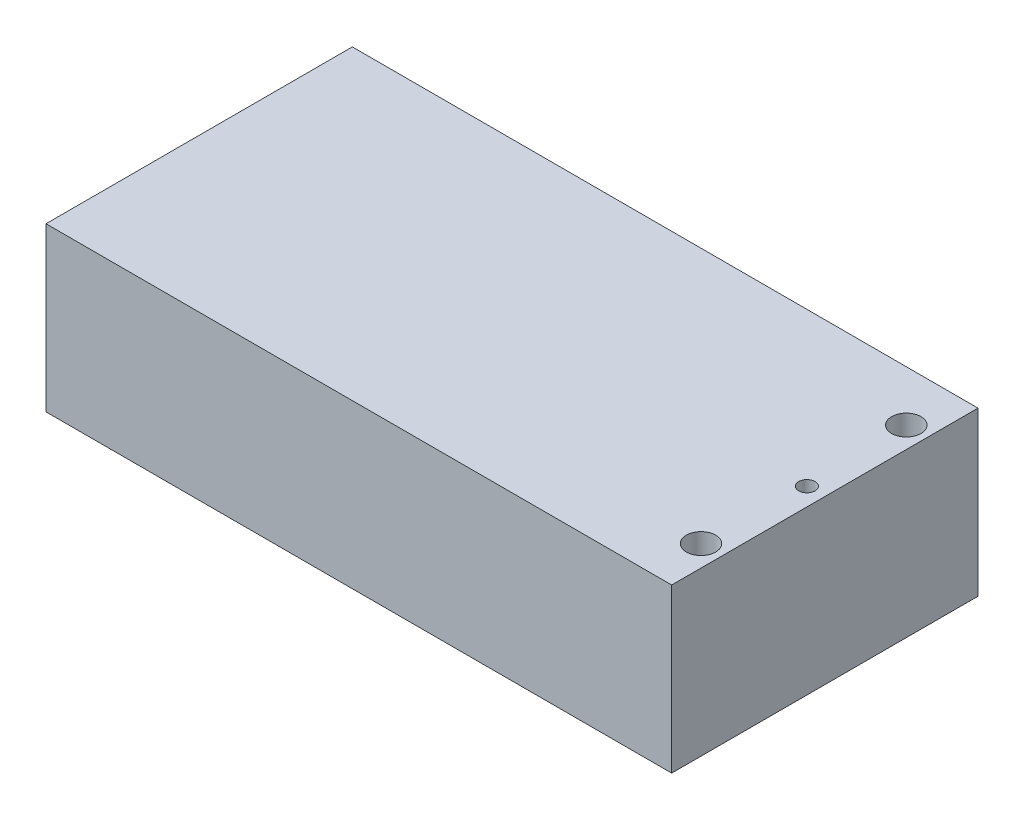
from build123d import *

# Parameters (mm, degrees)
SKETCH1_W           = 96
SKETCH1_H           = 47
BOSS_EXTRUDE1_DEPTH = 25
SKETCH2_R           = 2.25
SKETCH2_R_2         = 1.25
CUT_EXTRUDE1_DEPTH  = 10


with BuildPart() as part:
    # Sketch1 → Boss-Extrude1 (new body)
    with BuildSketch(Plane(origin=(0, 0, 0), x_dir=(1, 0, 0), z_dir=(0, 1, 0))):
        Rectangle(SKETCH1_W, SKETCH1_H)
    extrude(amount=BOSS_EXTRUDE1_DEPTH)

    # Sketch2 → Cut-Extrude1 (cut)
    with BuildSketch(Plane(origin=(0, 25, 0), x_dir=(1, 0, 0), z_dir=(0, 1, 0))):
        with Locations((44.75, 15.75)):
            Circle(SKETCH2_R)
        with Locations((44.75, -15.75)):
            Circle(SKETCH2_R)
        with Locations((45.25, 0)):
            Circle(SKETCH2_R_2)
    extrude(amount=-CUT_EXTRUDE1_DEPTH, mode=Mode.SUBTRACT)


solid = part.part
